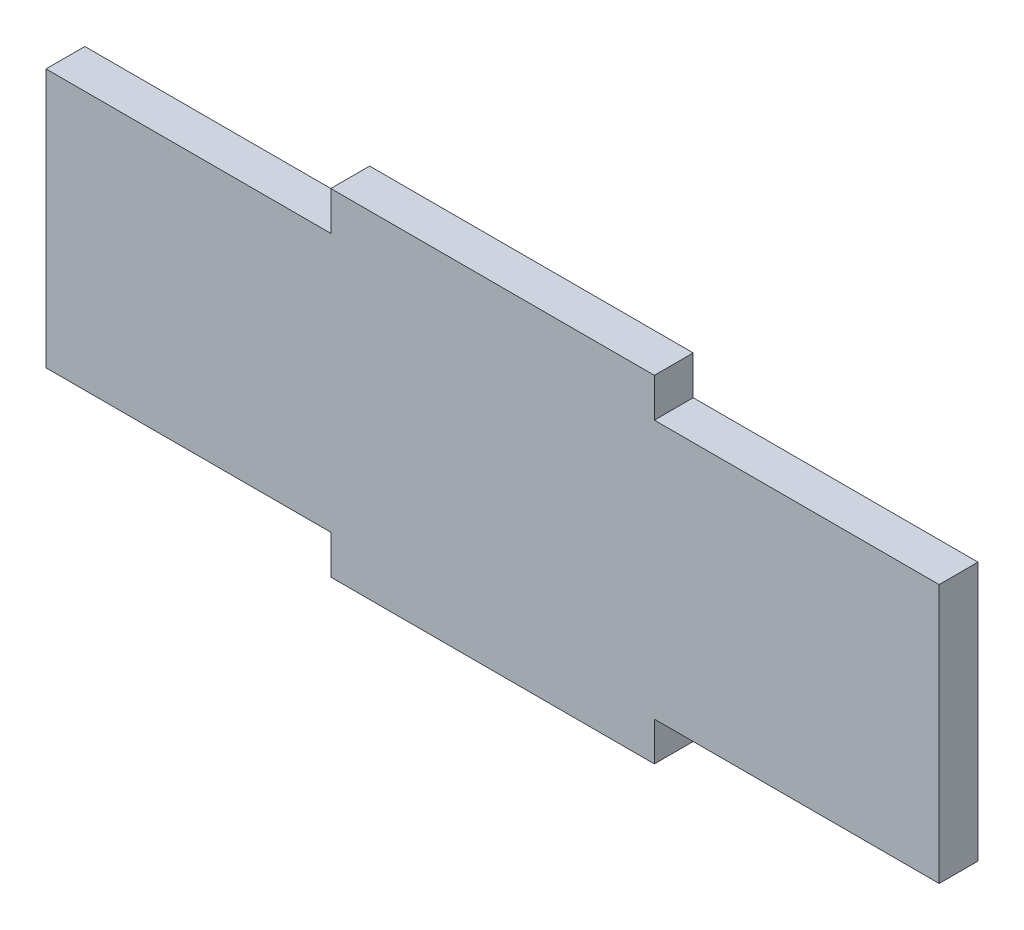
from build123d import *

# Parameters (mm, degrees)
ESQUISSE1_W        = 138
ESQUISSE1_H        = 40
BOSS_EXTRU_1_DEPTH = 6
ESQUISSE2_W        = 50
ESQUISSE2_H        = 6
BOSS_EXTRU_2_DEPTH = 6


with BuildPart() as part:
    # Esquisse1 → Boss.-Extru.1 (new body)
    with BuildSketch(Plane.XY):
        Rectangle(ESQUISSE1_W, ESQUISSE1_H)
    extrude(amount=BOSS_EXTRU_1_DEPTH)

    # Esquisse2 → Boss.-Extru.2 (add)
    with BuildSketch(Plane.XY.offset(6)):
        with Locations((0, 23)):
            Rectangle(ESQUISSE2_W, ESQUISSE2_H)
        with Locations((0, -23)):
            Rectangle(ESQUISSE2_W, ESQUISSE2_H)
    extrude(amount=-BOSS_EXTRU_2_DEPTH)


solid = part.part
